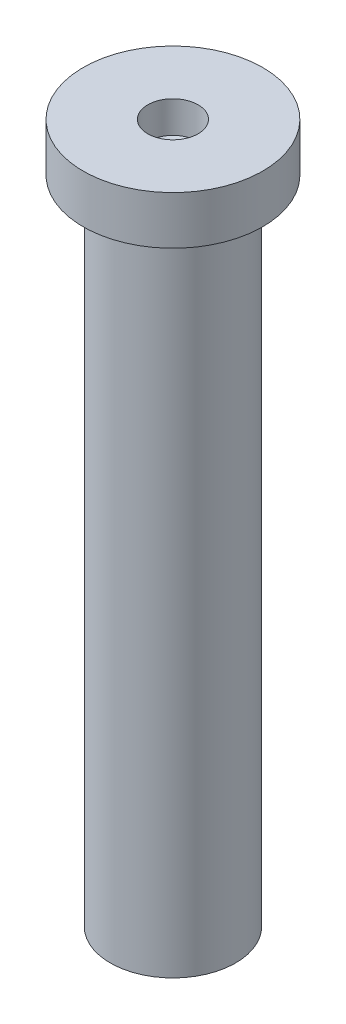
from build123d import *


with BuildPart() as part:
    # Sketch1 → Revolve1 (revolve)
    with BuildSketch(Plane.XY):
        Polygon((0.521941773, 12.942721083), (0.521941773, 12.284153462), (0, 11.818772418), (0, -1.557278917), (1.3, -1.557278917), (1.3, 11.942721083), (1.861447904, 11.942721083), (1.861447904, 12.942721083), align=None)
    revolve(axis=Axis((0, -1.557278917, 0), (0, 1, 0)))


solid = part.part
